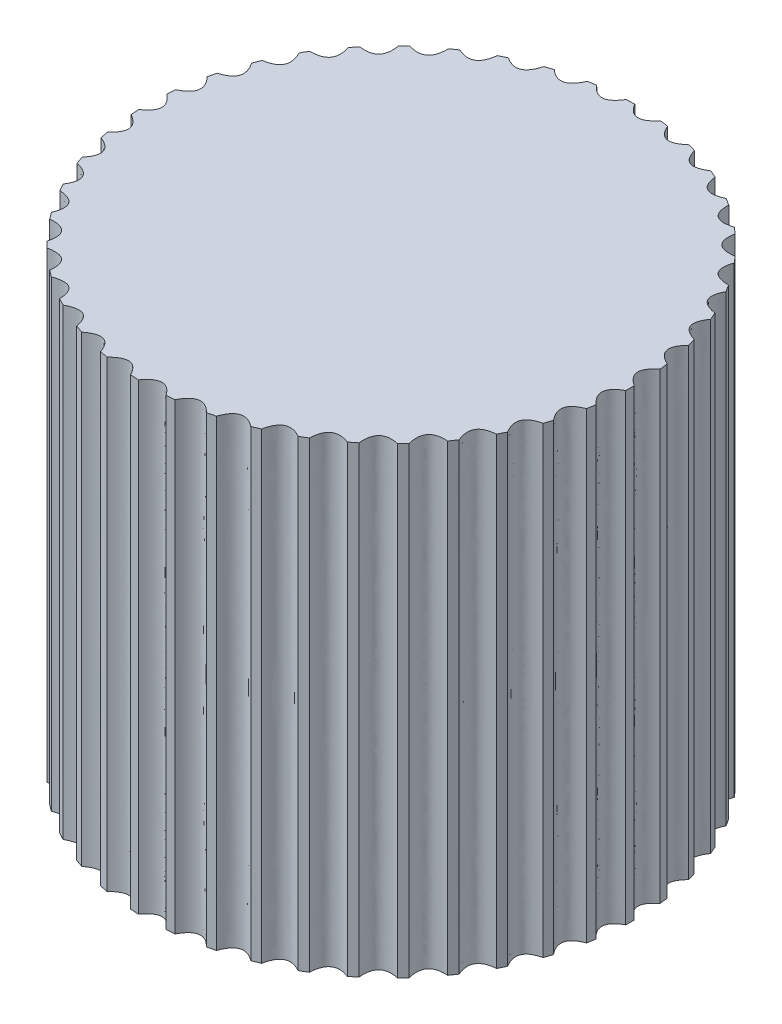
from build123d import *

# Parameters (mm, degrees)
EXTRUDE_1_DEPTH = 19


with BuildPart() as part:
    # 草图1 → 凸台-拉伸1 (new body)
    with BuildSketch(Plane(origin=(0, 0, 0), x_dir=(1, 0, 0), z_dir=(0, 1, 0))):
        with BuildLine():
            add(Edge.make_bspline(
                [(0, 10), (0.489904901, 9.196366596), (1.119723116, 9.93711327)],
                knots=[0, 0, 0, 1, 1, 1], degree=2))
            add(Edge.make_bspline(
                [(1.119723116, 9.93711327), (1.456011677, 9.893433681)],
                knots=[0, 0, 1, 1], degree=1))
            add(Edge.make_bspline(
                [(1.456011677, 9.893433681), (1.82368588, 9.027033577), (2.554645935, 9.668184118)],
                knots=[0, 0, 0, 1, 1, 1], degree=2))
            add(Edge.make_bspline(
                [(2.554645935, 9.668184118), (2.880990994, 9.576005999)],
                knots=[0, 0, 1, 1], degree=1))
            add(Edge.make_bspline(
                [(2.880990994, 9.576005999), (3.118598161, 8.665305009), (3.935120911, 9.193194408)],
                knots=[0, 0, 0, 1, 1, 1], degree=2))
            add(Edge.make_bspline(
                [(3.935120911, 9.193194408), (4.244566989, 9.054482375)],
                knots=[0, 0, 1, 1], degree=1))
            add(Edge.make_bspline(
                [(4.244566989, 9.054482375), (4.347042936, 8.118890509), (5.231725617, 8.522267719)],
                knots=[0, 0, 0, 1, 1, 1], degree=2))
            add(Edge.make_bspline(
                [(5.231725617, 8.522267719), (5.517677408, 8.339978179)],
                knots=[0, 0, 1, 1], degree=1))
            add(Edge.make_bspline(
                [(5.517677408, 8.339978179), (5.482838038, 7.399435953), (6.416825174, 7.66970369)],
                knots=[0, 0, 0, 1, 1, 1], degree=2))
            add(Edge.make_bspline(
                [(6.416825174, 7.66970369), (6.673188112, 7.447721827)],
                knots=[0, 0, 1, 1], degree=1))
            add(Edge.make_bspline(
                [(6.673188112, 7.447721827), (6.501775967, 6.522275267), (7.465161243, 6.653673242)],
                knots=[0, 0, 0, 1, 1, 1], degree=2))
            add(Edge.make_bspline(
                [(7.465161243, 6.653673242), (7.686471398, 6.396730216)],
                knots=[0, 0, 1, 1], degree=1))
            add(Edge.make_bspline(
                [(7.686471398, 6.396730216), (7.382139829, 5.506103607), (8.354390361, 5.495831301)],
                knots=[0, 0, 0, 1, 1, 1], degree=2))
            add(Edge.make_bspline(
                [(8.354390361, 5.495831301), (8.53593089, 5.209403405)],
                knots=[0, 0, 1, 1], degree=1))
            add(Edge.make_bspline(
                [(8.53593089, 5.209403405), (8.105166196, 4.372578908), (9.065560154, 4.220855257)],
                knots=[0, 0, 0, 1, 1, 1], degree=2))
            add(Edge.make_bspline(
                [(9.065560154, 4.220855257), (9.203461836, 3.911047205)],
                knots=[0, 0, 1, 1], degree=1))
            add(Edge.make_bspline(
                [(9.203461836, 3.911047205), (8.655445019, 3.145860281), (9.58351327, 2.855919012)],
                knots=[0, 0, 0, 1, 1, 1], degree=2))
            add(Edge.make_bspline(
                [(9.58351327, 2.855919012), (9.674836971, 2.529333824)],
                knots=[0, 0, 1, 1], degree=1))
            add(Edge.make_bspline(
                [(9.674836971, 2.529333824), (9.021248057, 1.852093104), (9.89721044, 1.430113811)],
                knots=[0, 0, 0, 1, 1, 1], degree=2))
            add(Edge.make_bspline(
                [(9.89721044, 1.430113811), (9.940009752, 1.093712084)],
                knots=[0, 0, 1, 1], degree=1))
            add(Edge.make_bspline(
                [(9.940009752, 1.093712084), (9.194778856, 0.518851778), (9.999965752, -0.026171783)],
                knots=[0, 0, 0, 1, 1, 1], degree=2))
            add(Edge.make_bspline(
                [(9.999965752, -0.026171783), (9.993328484, -0.365220231)],
                knots=[0, 0, 1, 1], degree=1))
            add(Edge.make_bspline(
                [(9.993328484, -0.365220231), (9.172338907, -0.825447973), (9.889589155, -1.481899571)],
                knots=[0, 0, 0, 1, 1, 1], degree=2))
            add(Edge.make_bspline(
                [(9.889589155, -1.481899571), (9.833656768, -1.81636851)],
                knots=[0, 0, 1, 1], degree=1))
            add(Edge.make_bspline(
                [(9.833656768, -1.81636851), (8.954406479, -2.152154733), (9.568433136, -2.906043242)],
                knots=[0, 0, 0, 1, 1, 1], degree=2))
            add(Edge.make_bspline(
                [(9.464397732, -3.228804048), (9.568433136, -2.906043242)],
                knots=[0, 0, 1, 1], degree=1))
            add(Edge.make_bspline(
                [(9.464397732, -3.228804048), (8.545626422, -3.432992052), (9.043342576, -4.268249646)],
                knots=[0, 0, 0, 1, 1, 1], degree=2))
            add(Edge.make_bspline(
                [(8.893421489, -4.572423233), (9.043342576, -4.268249646)],
                knots=[0, 0, 1, 1], degree=1))
            add(Edge.make_bspline(
                [(8.893421489, -4.572423233), (7.954711175, -4.640661106), (8.325508871, -5.53948572)],
                knots=[0, 0, 0, 1, 1, 1], degree=2))
            add(Edge.make_bspline(
                [(8.132897407, -5.818589156), (8.325508871, -5.53948572)],
                knots=[0, 0, 1, 1], degree=1))
            add(Edge.make_bspline(
                [(8.132897407, -5.818589156), (7.19425507, -5.749422524), (7.430231397, -6.692657274)],
                knots=[0, 0, 0, 1, 1, 1], degree=2))
            add(Edge.make_bspline(
                [(7.199034738, -6.940741952), (7.430231397, -6.692657274)],
                knots=[0, 0, 1, 1], degree=1))
            add(Edge.make_bspline(
                [(7.199034738, -6.940741952), (6.280465909, -6.735644984), (6.376591442, -7.703186456)],
                knots=[0, 0, 0, 1, 1, 1], degree=2))
            add(Edge.make_bspline(
                [(6.111737141, -7.914964884), (6.376591442, -7.703186456)],
                knots=[0, 0, 1, 1], degree=1))
            add(Edge.make_bspline(
                [(6.111737141, -7.914964884), (5.23281952, -7.578308865), (5.187045511, -8.549535594)],
                knots=[0, 0, 0, 1, 1, 1], degree=2))
            add(Edge.make_bspline(
                [(4.894178478, -8.720494081), (5.187045511, -8.549535594)],
                knots=[0, 0, 1, 1], degree=1))
            add(Edge.make_bspline(
                [(4.894178478, -8.720494081), (4.073644668, -8.259454249), (3.88694671, -9.213666223)],
                knots=[0, 0, 0, 1, 1, 1], degree=2))
            add(Edge.make_bspline(
                [(3.572308898, -9.340161087), (3.88694671, -9.213666223)],
                knots=[0, 0, 1, 1], degree=1))
            add(Edge.make_bspline(
                [(3.572308898, -9.340161087), (2.827647153, -8.764563706), (2.504004388, -9.681423554)],
                knots=[0, 0, 0, 1, 1, 1], degree=2))
            add(Edge.make_bspline(
                [(2.174301756, -9.760758776), (2.504004388, -9.681423554)],
                knots=[0, 0, 1, 1], degree=1))
            add(Edge.make_bspline(
                [(2.174301756, -9.760758776), (1.521383248, -9.082871704), (1.06769356, -9.942838149)],
                knots=[0, 0, 0, 1, 1, 1], degree=2))
            add(Edge.make_bspline(
                [(0.729953147, -9.973322837), (1.06769356, -9.942838149)],
                knots=[0, 0, 1, 1], degree=1))
            add(Edge.make_bspline(
                [(0.729953147, -9.973322837), (0.1826937, -9.207594061), (-0.391373302, -9.992338412)],
                knots=[0, 0, 0, 1, 1, 1], degree=2))
            add(Edge.make_bspline(
                [(-0.729953147, -9.973322837), (-0.391373302, -9.992338412)],
                knots=[0, 0, 1, 1], degree=1))
            add(Edge.make_bspline(
                [(-0.729953147, -9.973322837), (-1.159889647, -9.136072536), (-1.842098722, -9.82886933)],
                knots=[0, 0, 0, 1, 1, 1], degree=2))
            add(Edge.make_bspline(
                [(-2.174301756, -9.760758776), (-1.842098722, -9.82886933)],
                knots=[0, 0, 1, 1], degree=1))
            add(Edge.make_bspline(
                [(-2.174301756, -9.760758776), (-2.47775196, -8.869831487), (-3.253563006, -9.455914962)],
                knots=[0, 0, 0, 1, 1, 1], degree=2))
            add(Edge.make_bspline(
                [(-3.572308898, -9.340161087), (-3.253563006, -9.455914962)],
                knots=[0, 0, 1, 1], degree=1))
            add(Edge.make_bspline(
                [(-3.572308898, -9.340161087), (-3.742805291, -8.414545379), (-4.595683243, -8.881424184)],
                knots=[0, 0, 0, 1, 1, 1], degree=2))
            add(Edge.make_bspline(
                [(-4.894178478, -8.720494081), (-4.595683243, -8.881424184)],
                knots=[0, 0, 1, 1], degree=1))
            add(Edge.make_bspline(
                [(-4.894178478, -8.720494081), (-4.928087226, -7.779917845), (-5.83985447, -8.117641269)],
                knots=[0, 0, 0, 1, 1, 1], degree=2))
            add(Edge.make_bspline(
                [(-6.111737141, -7.914964884), (-5.83985447, -8.117641269)],
                knots=[0, 0, 1, 1], degree=1))
            add(Edge.make_bspline(
                [(-6.111737141, -7.914964884), (-6.008335537, -6.979474869), (-6.959559339, -7.180844923)],
                knots=[0, 0, 0, 1, 1, 1], degree=2))
            add(Edge.make_bspline(
                [(-7.199034738, -6.940741952), (-6.959559339, -7.180844923)],
                knots=[0, 0, 1, 1], degree=1))
            add(Edge.make_bspline(
                [(-7.199034738, -6.940741952), (-6.960526608, -6.030276504), (-7.930933283, -6.091001335)],
                knots=[0, 0, 0, 1, 1, 1], degree=2))
            add(Edge.make_bspline(
                [(-8.132897407, -5.818589156), (-7.930933283, -6.091001335)],
                knots=[0, 0, 1, 1], degree=1))
            add(Edge.make_bspline(
                [(-8.132897407, -5.818589156), (-7.764366139, -4.952553265), (-8.733273153, -4.871338629)],
                knots=[0, 0, 0, 1, 1, 1], degree=2))
            add(Edge.make_bspline(
                [(-8.893421489, -4.572423233), (-8.733273153, -4.871338629)],
                knots=[0, 0, 1, 1], degree=1))
            add(Edge.make_bspline(
                [(-8.893421489, -4.572423233), (-8.402721685, -3.769274951), (-9.349478468, -3.547851797)],
                knots=[0, 0, 0, 1, 1, 1], degree=2))
            add(Edge.make_bspline(
                [(-9.464397732, -3.228804048), (-9.349478468, -3.547851797)],
                knots=[0, 0, 1, 1], degree=1))
            add(Edge.make_bspline(
                [(-9.464397732, -3.228804048), (-8.861987808, -2.505661086), (-9.766415882, -2.148748663)],
                knots=[0, 0, 0, 1, 1, 1], degree=2))
            add(Edge.make_bspline(
                [(-9.833656768, -1.81636851), (-9.766415882, -2.148748663)],
                knots=[0, 0, 1, 1], degree=1))
            add(Edge.make_bspline(
                [(-9.833656768, -1.81636851), (-9.132376046, -1.188643405), (-9.975199097, -0.703848683)],
                knots=[0, 0, 0, 1, 1, 1], degree=2))
            add(Edge.make_bspline(
                [(-9.993328484, -0.365220231), (-9.975199097, -0.703848683)],
                knots=[0, 0, 1, 1], degree=1))
            add(Edge.make_bspline(
                [(-9.993328484, -0.365220231), (-9.208123543, 0.153708147), (-9.971378262, 0.756052611)],
                knots=[0, 0, 0, 1, 1, 1], degree=2))
            add(Edge.make_bspline(
                [(-9.940009752, 1.093712084), (-9.971378262, 0.756052611)],
                knots=[0, 0, 1, 1], degree=1))
            add(Edge.make_bspline(
                [(-9.940009752, 1.093712084), (-9.087615874, 1.492783677), (-9.755034811, 2.199839955)],
                knots=[0, 0, 0, 1, 1, 1], degree=2))
            add(Edge.make_bspline(
                [(-9.674836971, 2.529333824), (-9.755034811, 2.199839955)],
                knots=[0, 0, 1, 1], degree=1))
            add(Edge.make_bspline(
                [(-9.674836971, 2.529333824), (-8.77342145, 2.800043114), (-9.33077973, 3.59674153)],
                knots=[0, 0, 0, 1, 1, 1], degree=2))
            add(Edge.make_bspline(
                [(-9.203461836, 3.911047205), (-9.33077973, 3.59674153)],
                knots=[0, 0, 1, 1], degree=1))
            add(Edge.make_bspline(
                [(-9.203461836, 3.911047205), (-8.27223678, 4.047624493), (-8.707655278, 4.916984804)],
                knots=[0, 0, 0, 1, 1, 1], degree=2))
            add(Edge.make_bspline(
                [(-8.707655278, 4.916984804), (-8.659447626, 5.082349284), (-8.53593089, 5.209403405)],
                knots=[0, 0, 0, 1, 1, 1], degree=2))
            add(Edge.make_bspline(
                [(-8.53593089, 5.209403405), (-7.594743745, 5.208937783), (-7.898942271, 6.132431084)],
                knots=[0, 0, 0, 1, 1, 1], degree=2))
            add(Edge.make_bspline(
                [(-7.686471398, 6.396730216), (-7.898942271, 6.132431084)],
                knots=[0, 0, 1, 1], degree=1))
            add(Edge.make_bspline(
                [(-7.686471398, 6.396730216), (-6.755381932, 6.259231609), (-6.921877024, 7.217175241)],
                knots=[0, 0, 0, 1, 1, 1], degree=2))
            add(Edge.make_bspline(
                [(-6.673188112, 7.447721827), (-6.921877024, 7.217175241)],
                knots=[0, 0, 1, 1], degree=1))
            add(Edge.make_bspline(
                [(-6.673188112, 7.447721827), (-5.772040882, 7.176120779), (-5.797283986, 8.148097839)],
                knots=[0, 0, 0, 1, 1, 1], degree=2))
            add(Edge.make_bspline(
                [(-5.517677408, 8.339978179), (-5.797283986, 8.148097839)],
                knots=[0, 0, 1, 1], degree=1))
            add(Edge.make_bspline(
                [(-5.517677408, 8.339978179), (-4.665678802, 7.940063394), (-4.549131904, 8.905357877)],
                knots=[0, 0, 0, 1, 1, 1], degree=2))
            add(Edge.make_bspline(
                [(-4.549131904, 8.905357877), (-4.244566989, 9.054482375)],
                knots=[0, 0, 1, 1], degree=1))
            add(Edge.make_bspline(
                [(-4.244566989, 9.054482375), (-3.459875878, 8.534777343), (-3.204022973, 9.472815674)],
                knots=[0, 0, 0, 1, 1, 1], degree=2))
            add(Edge.make_bspline(
                [(-3.204022973, 9.472815674), (-2.880990994, 9.576005999)],
                knots=[0, 0, 1, 1], degree=1))
            add(Edge.make_bspline(
                [(-2.880990994, 9.576005999), (-2.180331707, 8.94758733), (-1.790625856, 9.83837685)],
                knots=[0, 0, 0, 1, 1, 1], degree=2))
            add(Edge.make_bspline(
                [(-1.790625856, 9.83837685), (-1.456011677, 9.893433681)],
                knots=[0, 0, 1, 1], degree=1))
            add(Edge.make_bspline(
                [(-1.456011677, 9.893433681), (-0.854317551, 9.169695028), (-0.339064658, 9.994250105)],
                knots=[0, 0, 0, 1, 1, 1], degree=2))
            add(Edge.make_bspline(
                [(-0.339064658, 9.994250105), (0, 10)],
                knots=[0, 0, 1, 1], degree=1))
        make_face()
    extrude(amount=EXTRUDE_1_DEPTH)


solid = part.part
